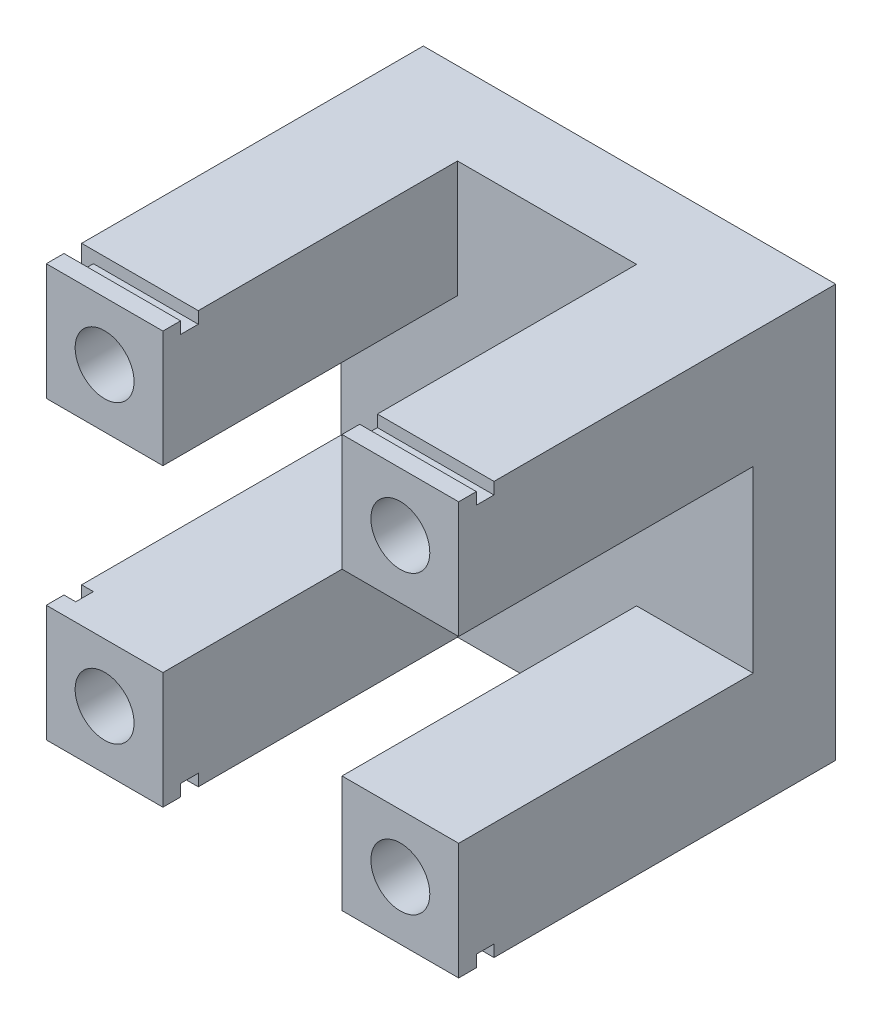
from build123d import *

# Parameters (mm, degrees)
ESQUISSE1_W                  = 70
ESQUISSE1_H                  = 70
BOSS_EXTRU_1_DEPTH           = 64
ESQUISSE2_W                  = 30.4
ESQUISSE2_H                  = 19.8
ESQUISSE2_H_2                = 30.4
ESQUISSE2_W_2                = 19.8
ENL_V_MAT_EXTRU_1_DEPTH      = 50
ESQUISSE5_W                  = 3
ESQUISSE5_H                  = 2
ENL_V_MAT_EXTRU_3_DEPTH      = 71
ESQUISSE6_W                  = 2
ESQUISSE6_H                  = 3
ENL_V_MAT_EXTRU_4_DEPTH      = 71
ESQUISSE7_R                  = 5
ENL_V_MAT_EXTRU_5_DEPTH      = 65
R_P_TITION_CIRCULAIRE2_COUNT = 4


with BuildPart() as part:
    # Esquisse1 → Boss.-Extru.1 (new body)
    with BuildSketch(Plane.XY):
        with Locations((-35, 35)):
            Rectangle(ESQUISSE1_W, ESQUISSE1_H)
    extrude(amount=BOSS_EXTRU_1_DEPTH)

    # Esquisse2 → Enlèv. mat.-Extru.1 (cut)
    with BuildSketch(Plane.XY.offset(64)):
        with Locations((-35, 60.1)):
            Rectangle(ESQUISSE2_W, ESQUISSE2_H)
        with Locations((-35, 35)):
            Rectangle(ESQUISSE2_W, ESQUISSE2_H_2)
        with Locations((-9.9, 35)):
            Rectangle(ESQUISSE2_W_2, ESQUISSE2_H_2)
        with Locations((-60.1, 35)):
            Rectangle(ESQUISSE2_W_2, ESQUISSE2_H_2)
        with Locations((-35, 9.9)):
            Rectangle(ESQUISSE2_W, ESQUISSE2_H)
    extrude(amount=-ENL_V_MAT_EXTRU_1_DEPTH, mode=Mode.SUBTRACT)

    # Esquisse5 → Enlèv. mat.-Extru.3 (cut, through all)
    with BuildSketch(Plane.ZY.offset(70)):
        with Locations((59.5, 69)):
            Rectangle(ESQUISSE5_W, ESQUISSE5_H)
        with Locations((59.5, 1)):
            Rectangle(ESQUISSE5_W, ESQUISSE5_H)
    extrude(amount=-ENL_V_MAT_EXTRU_3_DEPTH, mode=Mode.SUBTRACT)

    # Esquisse6 → Enlèv. mat.-Extru.4 (cut, through all)
    with BuildSketch(Plane(origin=(0, 70, 0), x_dir=(1, 0, 0), z_dir=(0, 1, 0))):
        with Locations((-69, -59.5)):
            Rectangle(ESQUISSE6_W, ESQUISSE6_H)
    extrude(amount=-ENL_V_MAT_EXTRU_4_DEPTH, mode=Mode.SUBTRACT)

    # Esquisse7 → Enlèv. mat.-Extru.5 (cut, through all)
    with BuildSketch(Plane.XY.offset(64)):
        with Locations((-9.9, 9.9)):
            Circle(ESQUISSE7_R)
    enl_v_mat_extru_5 = extrude(amount=-ENL_V_MAT_EXTRU_5_DEPTH, mode=Mode.SUBTRACT)

    # Répétition circulaire2: Enlèv. mat.-Extru.5 ×4 about axis
    r_p_tition_circulaire2_axis = Axis((-35, 35, 0), (0, 0, 1))
    for i in range(1, R_P_TITION_CIRCULAIRE2_COUNT):
        add(enl_v_mat_extru_5.rotate(r_p_tition_circulaire2_axis, i * 360 / R_P_TITION_CIRCULAIRE2_COUNT), mode=Mode.SUBTRACT)


solid = part.part
